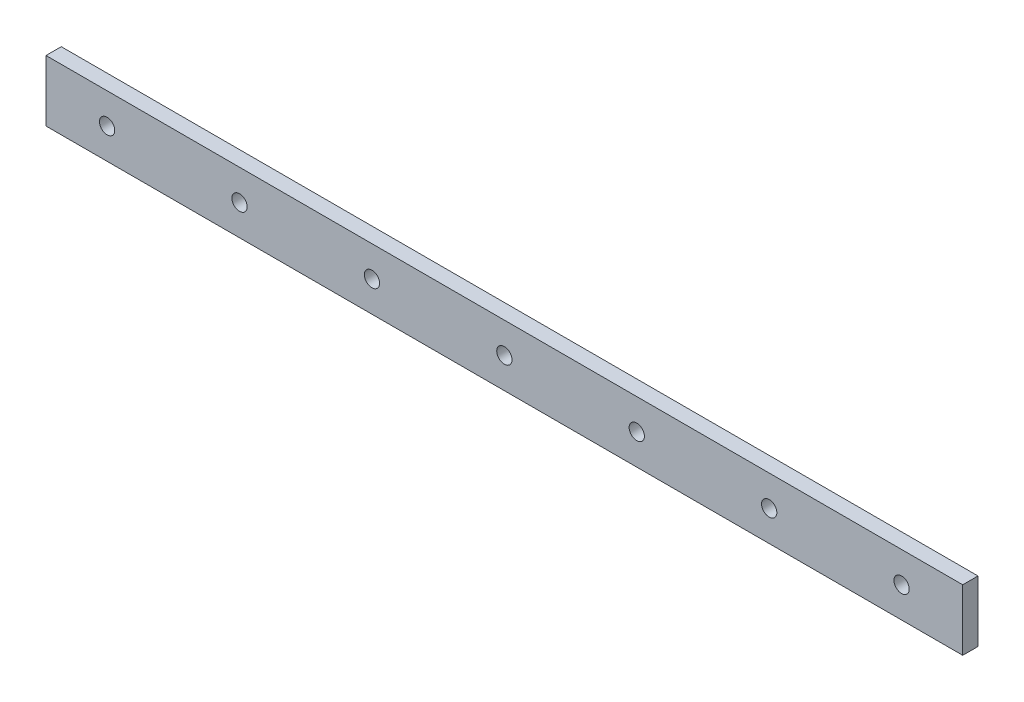
from build123d import *

# Parameters (mm, degrees)
SKICA1_W                = 300
SKICA1_H                = 20
P_IDAT_VYSUNUT_M1_DEPTH = 5
F_5_0_5_PR_M_R_D_RY1_D  = 5
F_5_0_5_PR_M_R_D_RY2_D  = 5
LINPOLE1_COUNT          = 6
LINPOLE1_PITCH          = 43.333333333


with BuildPart() as part:
    # Skica1 → Přidat vysunutím1 (new body)
    with BuildSketch(Plane.XY):
        Rectangle(SKICA1_W, SKICA1_H)
    extrude(amount=P_IDAT_VYSUNUT_M1_DEPTH)

    # Ø5.0 (5) průměr díry1 (through all)
    with Locations(Plane.XY.offset(5)):
        with Locations((-130, 0)):
            f_5_0_5_pr_m_r_d_ry1 = Hole(F_5_0_5_PR_M_R_D_RY1_D / 2)

    # Ø5.0 (5) průměr díry2 (through all)
    with Locations(Plane.XY.offset(5)):
        with Locations((130, 0)):
            Hole(F_5_0_5_PR_M_R_D_RY2_D / 2)

    # LinPole1: Ø5.0 (5) průměr díry1 ×6
    with Locations(*[(i * LINPOLE1_PITCH, 0, 0) for i in range(1, LINPOLE1_COUNT)]):
        add(f_5_0_5_pr_m_r_d_ry1, mode=Mode.SUBTRACT)


solid = part.part
